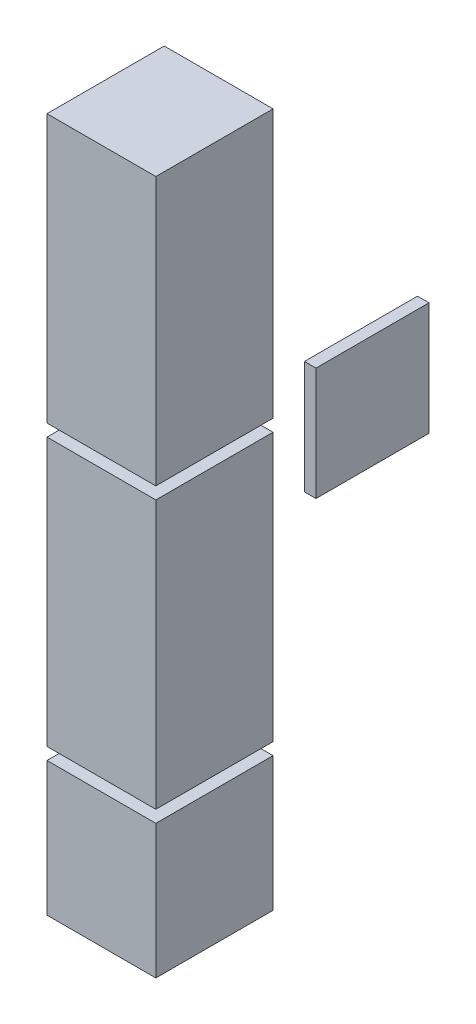
from build123d import *

# Parameters (mm, degrees)
SKETCH2_W             = 28
SKETCH2_H             = 64
BOSS_EXTRUDE2_DEPTH   = 26
BOSS_EXTRUDE2_2_DEPTH = 26
SKETCH2_H_2           = 32
BOSS_EXTRUDE2_3_DEPTH = 26
SKETCH3_W             = 27
SKETCH3_H             = 27
BOSS_EXTRUDE3_DEPTH   = 2.75


with BuildPart() as part:
    # Sketch2 → Boss-Extrude2 (new body)
    with BuildSketch(Plane(origin=(1.5875, 0, 0), x_dir=(0, 0, -1), z_dir=(1, 0, 0))):
        with Locations((9, 183)):
            Rectangle(SKETCH2_W, SKETCH2_H)
    extrude(amount=BOSS_EXTRUDE2_DEPTH)


with BuildPart() as body_2:
    # Sketch2 → Boss-Extrude2 2 (new body)
    with BuildSketch(Plane(origin=(1.5875, 0, 0), x_dir=(0, 0, -1), z_dir=(1, 0, 0))):
        with Locations((9, 116.1)):
            Rectangle(SKETCH2_W, SKETCH2_H)
    extrude(amount=BOSS_EXTRUDE2_2_DEPTH)


with BuildPart() as body_3:
    # Sketch2 → Boss-Extrude2 3 (new body)
    with BuildSketch(Plane(origin=(1.5875, 0, 0), x_dir=(0, 0, -1), z_dir=(1, 0, 0))):
        with Locations((9, 65.2)):
            Rectangle(SKETCH2_W, SKETCH2_H_2)
    extrude(amount=BOSS_EXTRUDE2_3_DEPTH)


with BuildPart() as body_4:
    # Sketch3 → Boss-Extrude3 (new body)
    with BuildSketch(Plane(origin=(1.5875, 0, 0), x_dir=(0, 0, -1), z_dir=(1, 0, 0))):
        with Locations((70, 119.5)):
            Rectangle(SKETCH3_W, SKETCH3_H)
    extrude(amount=BOSS_EXTRUDE3_DEPTH)


solid = Compound([part.part, body_2.part, body_3.part, body_4.part])
